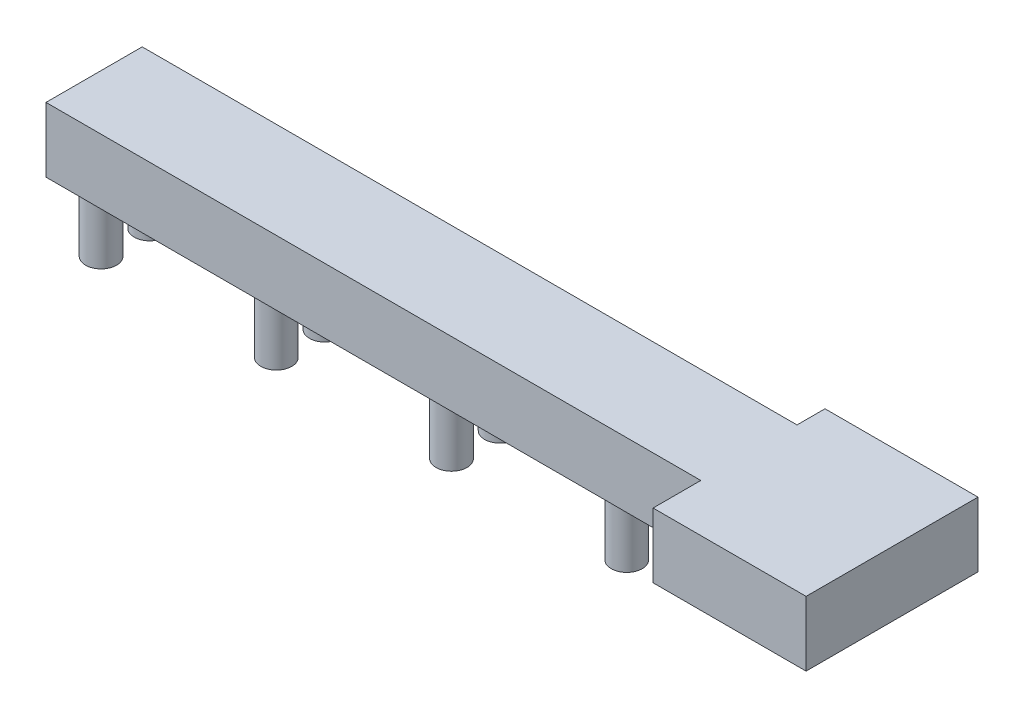
from build123d import *

# Parameters (mm, degrees)
EXTRUDE_1_DEPTH        = 10
SKETCH_3_R             = 2.392945251
SKETCH_3_R_2           = 2.39
EXTRUDE_2_DEPTH        = 10
PATTERN_LINEAR_1_COUNT = 4
PATTERN_LINEAR_1_PITCH = 27.05


with BuildPart() as part:
    # 草图1 → 凸台-拉伸1 (new body)
    with BuildSketch(Plane(origin=(0, 0, 0), x_dir=(1, 0, 0), z_dir=(0, 1, 0))):
        Polygon((-88.703690987, 0), (-88.703690987, 7.5), (-83.873690987, 7.5), (-56.823690987, 7.5), (-29.773690987, 7.5), (-2.723690987, 7.5), (12.386309013, 7.5), (12.386309013, 11.82), (36.006309013, 11.82), (36.006309013, -14.72), (12.386309013, -14.72), (12.386309013, -7.35), (-88.703690987, -7.35), align=None)
    extrude(amount=EXTRUDE_1_DEPTH)

    # 草图3 → 凸台-拉伸2 (add)
    with BuildSketch(Plane.XZ):
        with Locations((-83.873690987, 3.675)):
            Circle(SKETCH_3_R)
        with Locations((-83.873690987, -3.825)):
            Circle(SKETCH_3_R_2)
    extrude_2 = extrude(amount=EXTRUDE_2_DEPTH)

    # 阵列(线性)1: 凸台-拉伸2 ×4
    with Locations(*[(i * PATTERN_LINEAR_1_PITCH, 0, 0) for i in range(1, PATTERN_LINEAR_1_COUNT)]):
        add(extrude_2)


solid = part.part
